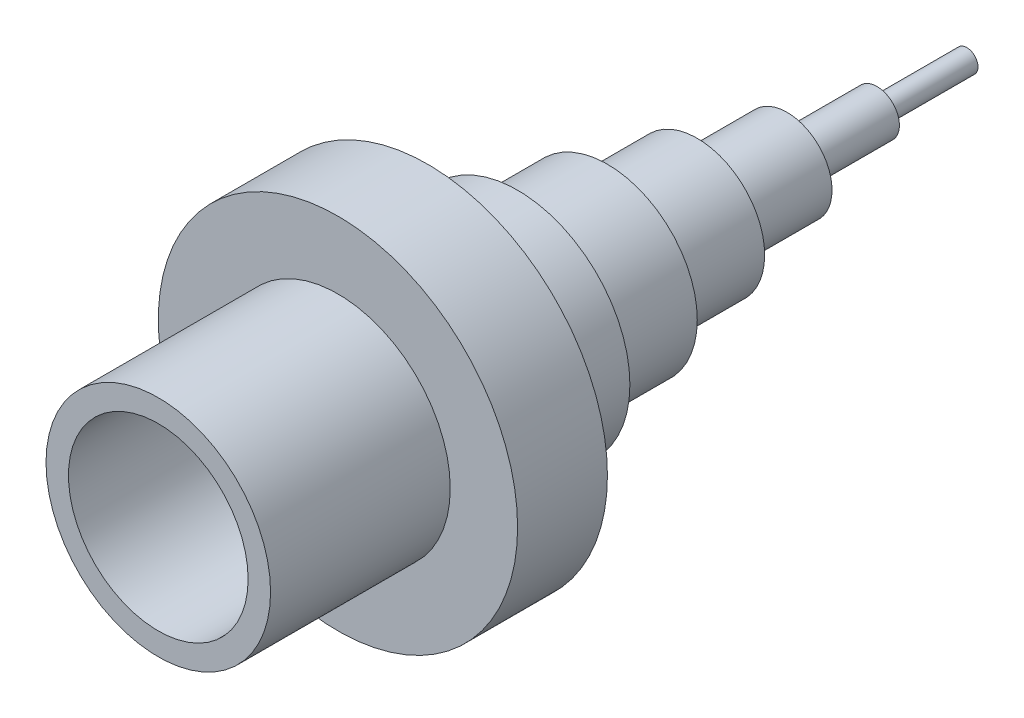
from build123d import *


with BuildPart() as part:
    # Croquis1 → Revolución1 (revolve)
    with BuildSketch(Plane(origin=(0, 0, 0), x_dir=(0, 0, -1), z_dir=(1, 0, 0))):
        Polygon((0, 25), (40, 25), (40, 40), (60, 40), (60, 25), (80, 25), (80, 20), (100, 20), (100, 15), (120, 15), (120, 10), (140, 10), (140, 5), (160, 5), (160, 2.5), (180, 2.5), (180, 0), (40, 0), (40, 20), (0, 20), align=None)
    revolve(axis=Axis((0, 0, 0), (0, 0, -1)))


solid = part.part
